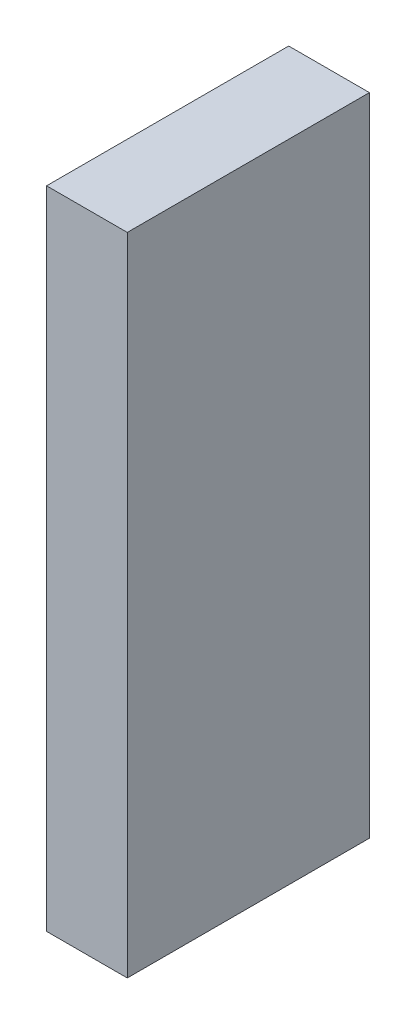
from build123d import *

# Parameters (mm, degrees)
SKETCH1_W           = 9.525
SKETCH1_H           = 25.4
BOSS_EXTRUDE1_DEPTH = 3.175


with BuildPart() as part:
    # Sketch1 → Boss-Extrude1 (new body)
    with BuildSketch(Plane(origin=(0, 0, 0), x_dir=(0, 0, -1), z_dir=(1, 0, 0))):
        Rectangle(SKETCH1_W, SKETCH1_H)
    extrude(amount=BOSS_EXTRUDE1_DEPTH)


solid = part.part
